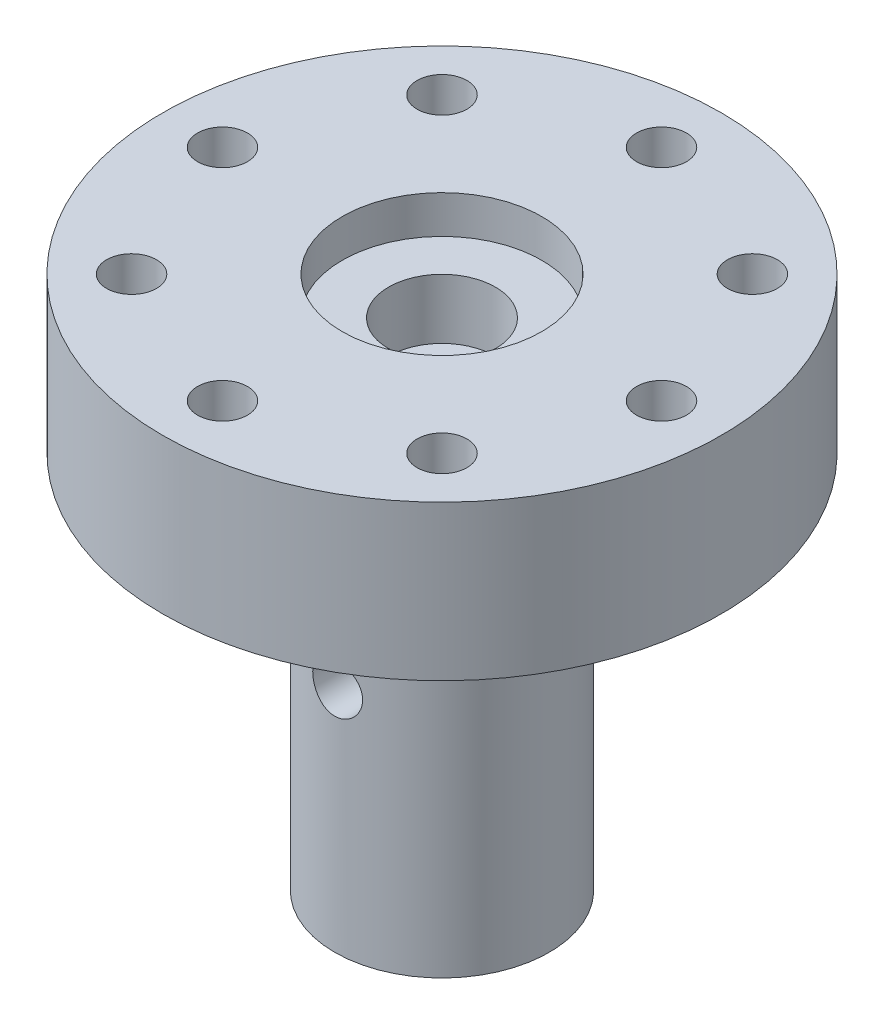
from build123d import *

# Parameters (mm, degrees)
SKETCH1_R               = 14
SKETCH1_R_2             = 1.25
BOSS_EXTRUDE1_DEPTH     = 7.75
SKETCH2_R               = 5
CUT_EXTRUDE1_DEPTH      = 1.9
SKETCH5_R               = 2.675
CUT_EXTRUDE3_DEPTH      = 3
SKETCH3_R               = 5.375
BOSS_EXTRUDE2_DEPTH     = 19
SKETCH4_R               = 1.25
CUT_EXTRUDE4_DEPTH      = 15
CUT_EXTRUDE4_DEPTH_BACK = 15


with BuildPart() as part:
    # Sketch1 → Boss-Extrude1 (new body)
    with BuildSketch(Plane(origin=(0, 0, 0), x_dir=(1, 0, 0), z_dir=(0, 1, 0))):
        Circle(SKETCH1_R)
        with Locations((-7.778174593, 7.778174593)):
            Circle(SKETCH1_R_2, mode=Mode.SUBTRACT)
        with Locations((0, 11)):
            Circle(SKETCH1_R_2, mode=Mode.SUBTRACT)
        with Locations((7.778174593, 7.778174593)):
            Circle(SKETCH1_R_2, mode=Mode.SUBTRACT)
        with Locations((11, 0)):
            Circle(SKETCH1_R_2, mode=Mode.SUBTRACT)
        with Locations((7.778174593, -7.778174593)):
            Circle(SKETCH1_R_2, mode=Mode.SUBTRACT)
        with Locations((0, -11)):
            Circle(SKETCH1_R_2, mode=Mode.SUBTRACT)
        with Locations((-11, 0)):
            Circle(SKETCH1_R_2, mode=Mode.SUBTRACT)
        with Locations((-7.778174593, -7.778174593)):
            Circle(SKETCH1_R_2, mode=Mode.SUBTRACT)
    extrude(amount=BOSS_EXTRUDE1_DEPTH)

    # Sketch2 → Cut-Extrude1 (cut)
    with BuildSketch(Plane(origin=(0, 7.75, 0), x_dir=(1, 0, 0), z_dir=(0, 1, 0))):
        Circle(SKETCH2_R)
    extrude(amount=-CUT_EXTRUDE1_DEPTH, mode=Mode.SUBTRACT)

    # Sketch5 → Cut-Extrude3 (cut)
    with BuildSketch(Plane(origin=(0, 5.85, 0), x_dir=(1, 0, 0), z_dir=(0, 1, 0))):
        Circle(SKETCH5_R)
    extrude(amount=-CUT_EXTRUDE3_DEPTH, mode=Mode.SUBTRACT)

    # Sketch3 → Boss-Extrude2 (add)
    with BuildSketch(Plane.XZ):
        Circle(SKETCH3_R)
    extrude(amount=BOSS_EXTRUDE2_DEPTH)

    # Sketch4 → Cut-Extrude4 (cut, two sides)
    with BuildSketch(Plane.XY) as cut_extrude4_sk:
        with Locations((0, -7.5)):
            Circle(SKETCH4_R)
    extrude(amount=CUT_EXTRUDE4_DEPTH, mode=Mode.SUBTRACT)
    extrude(cut_extrude4_sk.sketch, amount=-CUT_EXTRUDE4_DEPTH_BACK, mode=Mode.SUBTRACT)


solid = part.part
